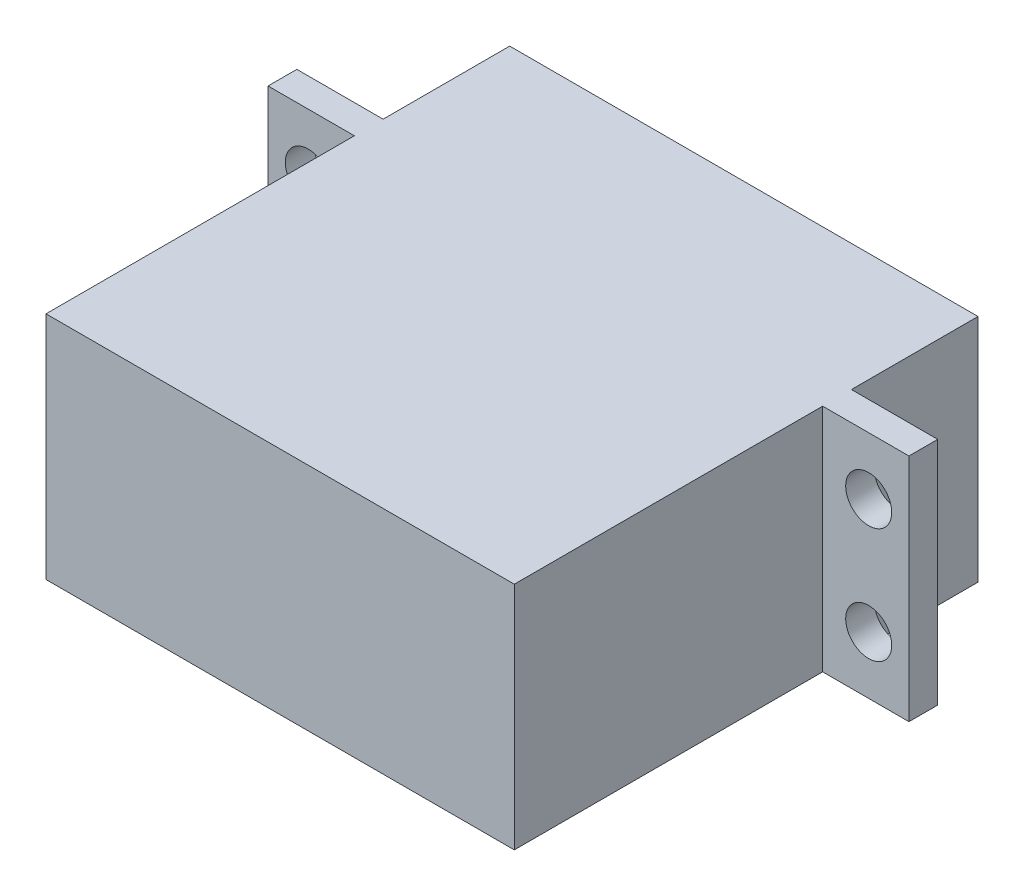
from build123d import *

# Parameters (mm, degrees)
SCHIZZO1_W                   = 40.7
SCHIZZO1_H                   = 20
ESTRUSIONE_ESTRUSIONE1_DEPTH = 40.3
SCHIZZO2_W                   = 2.5
SCHIZZO2_H                   = 20
ESTRUSIONE_ESTRUSIONE2_DEPTH = 7.5
RIPETIZIONE_A_L1_COUNT       = 2
RIPETIZIONE_A_L1_PITCH       = 48.2
SCHIZZO3_R                   = 3
ESTRUSIONE_ESTRUSIONE3_DEPTH = 4
SCHIZZO4_R                   = 2
TAGLIO_ESTRUSIONE1_DEPTH     = 10


with BuildPart() as part:
    # Schizzo1 → Estrusione-Estrusione1 (new body)
    with BuildSketch(Plane.XY):
        Rectangle(SCHIZZO1_W, SCHIZZO1_H)
    extrude(amount=ESTRUSIONE_ESTRUSIONE1_DEPTH)

    # Schizzo2 → Estrusione-Estrusione2 (add)
    with BuildSketch(Plane(origin=(20.35, 0, 0), x_dir=(0, 0, -1), z_dir=(1, 0, 0))):
        with Locations((-12.25, 0)):
            Rectangle(SCHIZZO2_W, SCHIZZO2_H)
    estrusione_estrusione2 = extrude(amount=ESTRUSIONE_ESTRUSIONE2_DEPTH)

    # Ripetizione a L1: Estrusione-Estrusione2 ×2
    with Locations(*[(-i * RIPETIZIONE_A_L1_PITCH, 0, 0) for i in range(1, RIPETIZIONE_A_L1_COUNT)]):
        add(estrusione_estrusione2)

    # Schizzo3 → Estrusione-Estrusione3 (add)
    with BuildSketch(Plane(origin=(0, 0, 0), x_dir=(-1, 0, 0), z_dir=(0, 0, -1))):
        with Locations((-10.35, 0)):
            Circle(SCHIZZO3_R)
    extrude(amount=ESTRUSIONE_ESTRUSIONE3_DEPTH)

    # Schizzo4 → Taglio-Estrusione1 (cut)
    with BuildSketch(Plane(origin=(0, 0, 11), x_dir=(-1, 0, 0), z_dir=(0, 0, -1))):
        with Locations((-24.35, 5)):
            Circle(SCHIZZO4_R)
        with Locations((-24.35, -5)):
            Circle(SCHIZZO4_R)
        with Locations((24.35, 5)):
            Circle(SCHIZZO4_R)
        with Locations((24.35, -5)):
            Circle(SCHIZZO4_R)
    extrude(amount=-TAGLIO_ESTRUSIONE1_DEPTH, mode=Mode.SUBTRACT)


solid = part.part
